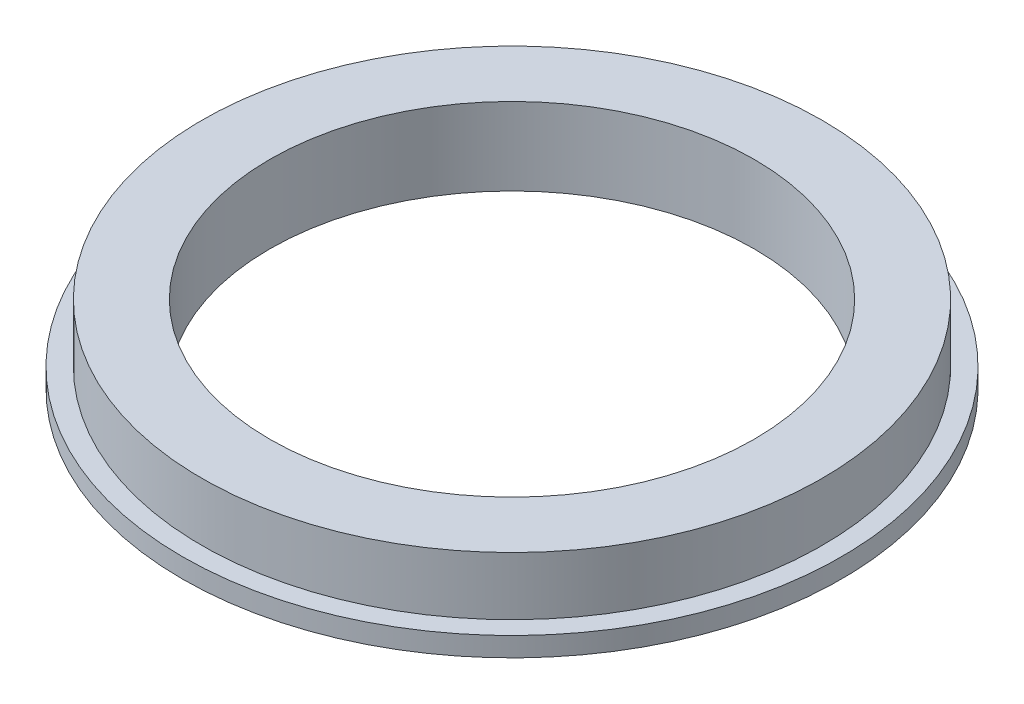
from build123d import *


with BuildPart() as part:
    # 草图2 → 旋转1 (revolve)
    with BuildSketch(Plane.XY):
        Polygon((12.5, 4), (16, 4), (16, 1), (17, 1), (17, 0), (12.5, 0), align=None)
    revolve(axis=Axis((0, -1.200890542, 0), (0, 1, 0)))


solid = part.part
